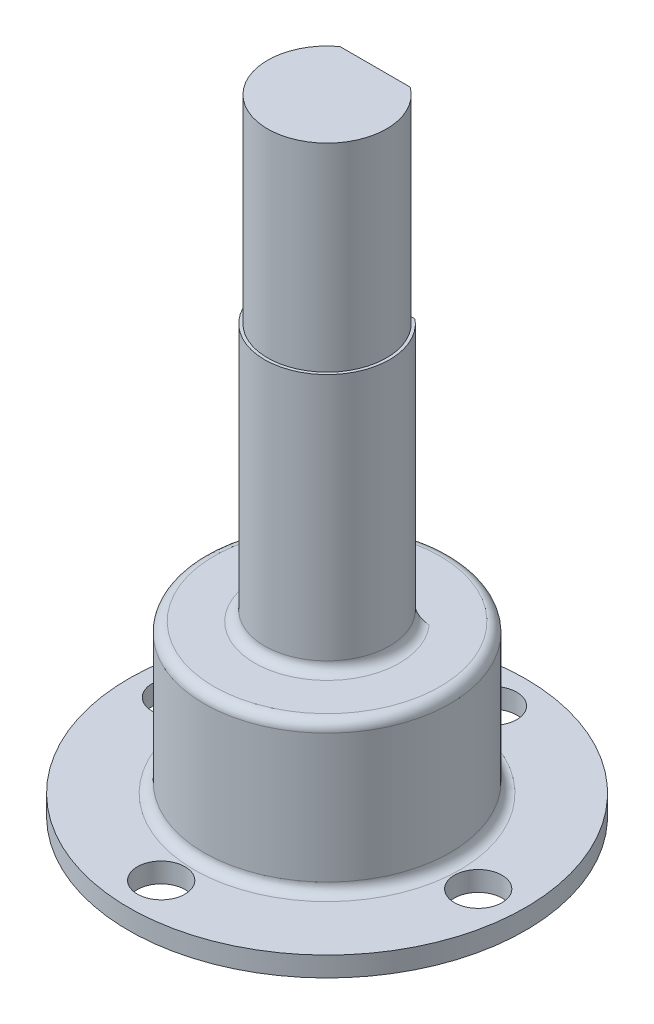
from build123d import *

# Parameters (mm, degrees)
ESQUISSE3_W                  = 6.57785754
ESQUISSE3_H                  = 1.386048805
ENL_V_MAT_EXTRU_1_DEPTH      = 23
M2_CLEARANCE_HOLE1_D         = 2.4
M2_CLEARANCE_HOLE1_DEPTH     = 1.001
R_P_TITION_CIRCULAIRE1_COUNT = 4
FILLET1_R                    = 0.5


with BuildPart() as part:
    # Esquisse2 → Révolution2 (revolve)
    with BuildSketch(Plane.XY):
        Polygon((0, 31.5), (3, 31.5), (3, 21.5), (3.15, 21.5), (3.15, 8.5), (6.2, 8.5), (6.2, 3), (6.2, 1), (10, 1), (10, 0), (4.5, 0), (4.5, 5), (0, 5), align=None)
    revolve(axis=Axis((0, 5, 0), (0, 1, 0)))

    # Esquisse3 → Enlèv. mat.-Extru.1 (cut)
    with BuildSketch(Plane(origin=(0, 31.5, 0), x_dir=(1, 0, 0), z_dir=(0, 1, 0))):
        with Locations((-0.352413472, 3.114928535)):
            Rectangle(ESQUISSE3_W, ESQUISSE3_H)
    extrude(amount=-ENL_V_MAT_EXTRU_1_DEPTH, mode=Mode.SUBTRACT)

    # M2 Clearance Hole1
    with Locations(Plane(origin=(0, 1, 0), x_dir=(1, 0, 0), z_dir=(0, 1, 0))):
        with Locations((0.371303159, 7.991378727)):
            m2_clearance_hole1 = Hole(M2_CLEARANCE_HOLE1_D / 2, depth=M2_CLEARANCE_HOLE1_DEPTH)

    # Répétition circulaire1: M2 Clearance Hole1 ×4 about axis
    r_p_tition_circulaire1_axis = Axis((0, 0, 0), (0, 1, 0))
    for i in range(1, R_P_TITION_CIRCULAIRE1_COUNT):
        add(m2_clearance_hole1.rotate(r_p_tition_circulaire1_axis, i * 360 / R_P_TITION_CIRCULAIRE1_COUNT), mode=Mode.SUBTRACT)

    # Fillet1
    fillet1_edges = [part.edges().sort_by_distance(p)[0] for p in [
        (-6.2, 1, 0),
        (-6.2, 8.5, 0),
        (0, 8.5, 3.15),
    ]]
    fillet(fillet1_edges, radius=FILLET1_R)


solid = part.part
